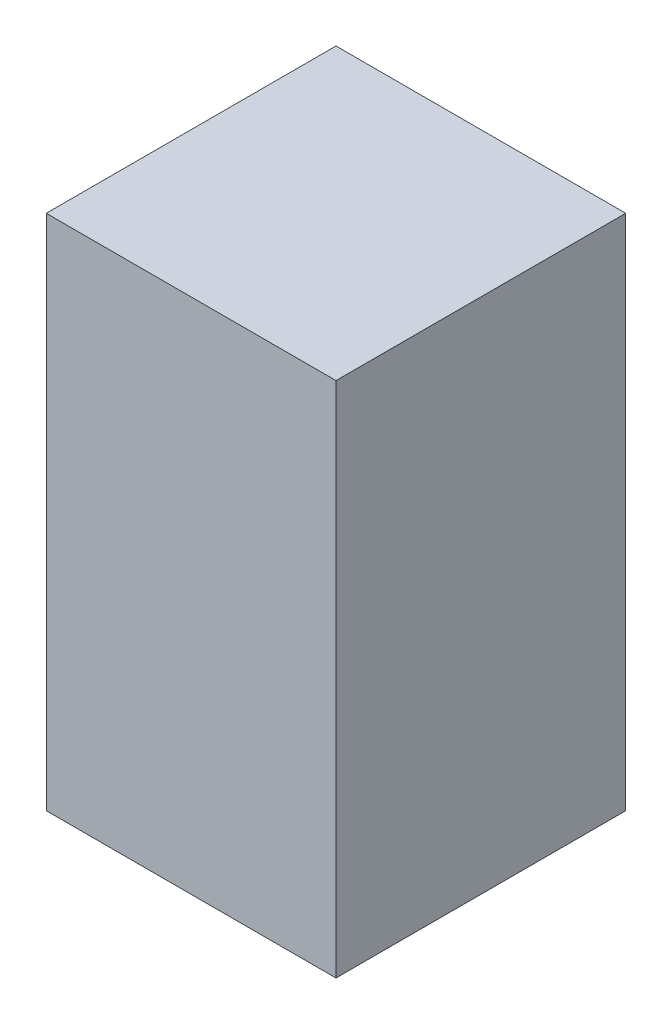
from build123d import *

# Parameters (mm, degrees)
SKETCH3_W           = 28
SKETCH3_H           = 50
BOSS_EXTRUDE1_DEPTH = 14
SKETCH6_R           = 12.5
CUT_EXTRUDE1_DEPTH  = 40


with BuildPart() as part:
    # Sketch3 → Boss-Extrude1 (new body, symmetric)
    with BuildSketch(Plane(origin=(0, 0, 0), x_dir=(0, 0, -1), z_dir=(1, 0, 0))):
        with Locations((14, 25)):
            Rectangle(SKETCH3_W, SKETCH3_H)
    extrude(amount=BOSS_EXTRUDE1_DEPTH, both=True)

    # Sketch6 → Cut-Extrude1 (cut)
    with BuildSketch(Plane(origin=(0, 0, 0), x_dir=(-1, 0, 0), z_dir=(0, -1, 0))):
        with Locations((0, 14)):
            Circle(SKETCH6_R)
    extrude(amount=-CUT_EXTRUDE1_DEPTH, mode=Mode.SUBTRACT)


solid = part.part
